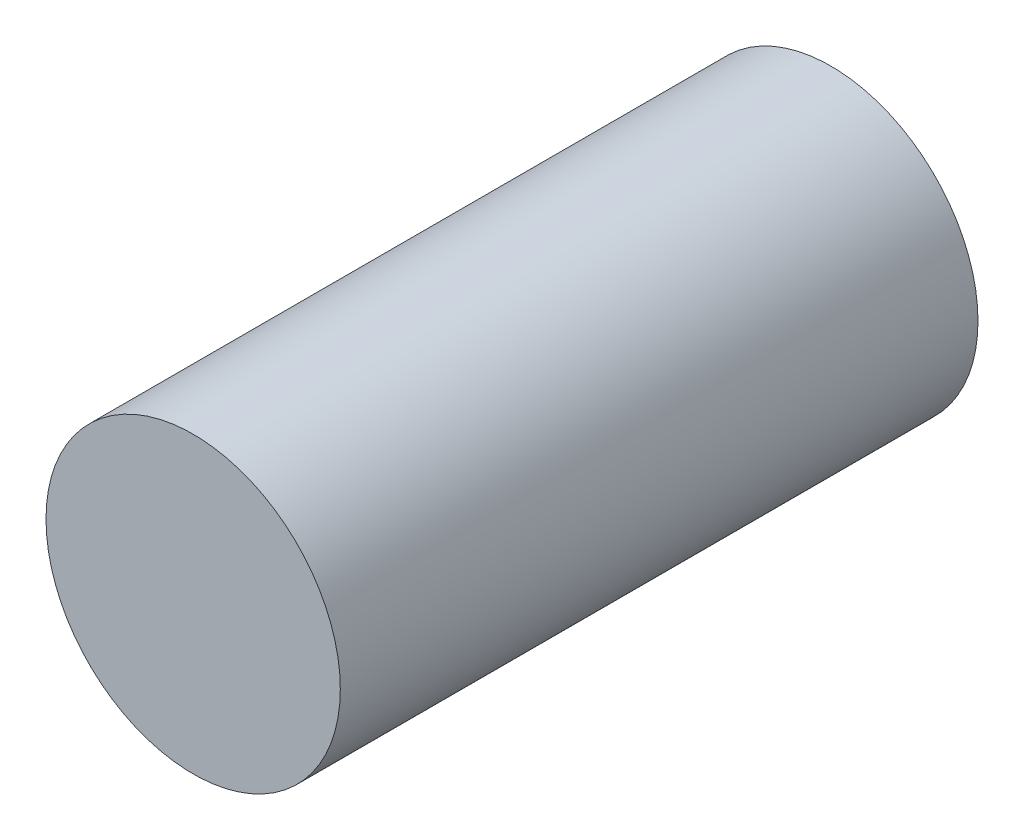
from build123d import *

# Parameters (mm, degrees)
SKETCH1_R           = 30
BOSS_EXTRUDE1_DEPTH = 130


with BuildPart() as part:
    # Sketch1 → Boss-Extrude1 (new body)
    with BuildSketch(Plane.XY):
        Circle(SKETCH1_R)
    extrude(amount=BOSS_EXTRUDE1_DEPTH)


solid = part.part
